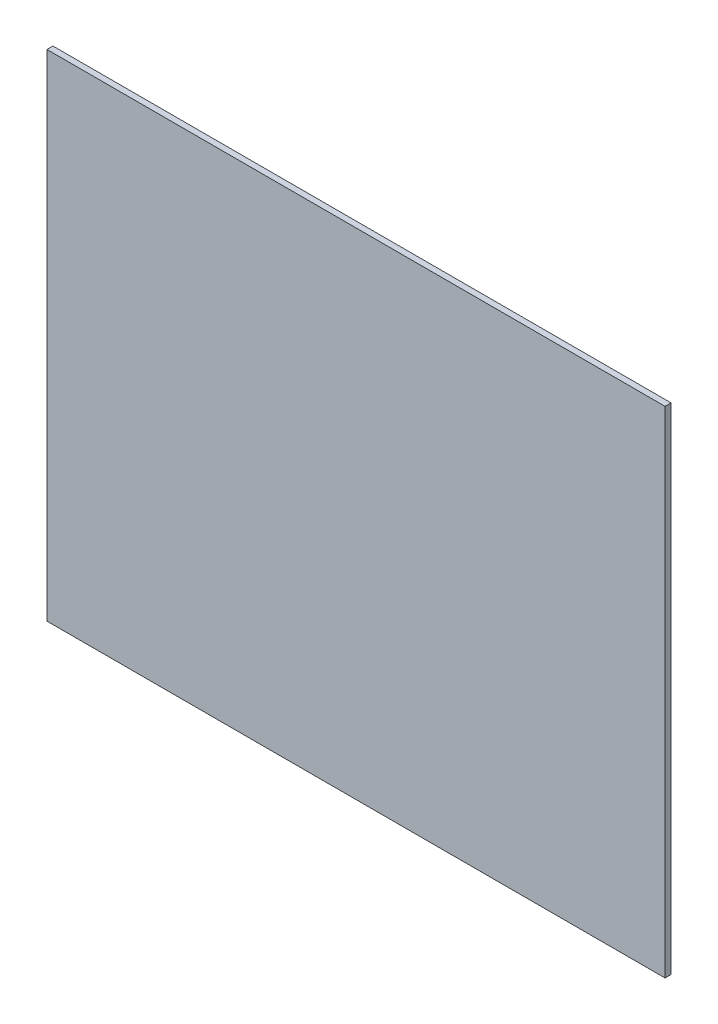
from build123d import *

# Parameters (mm, degrees)
CROQUIS1_W              = 412
CROQUIS1_H              = 330
SALIENTE_EXTRUIR1_DEPTH = 4


with BuildPart() as part:
    # Croquis1 → Saliente-Extruir1 (new body)
    with BuildSketch(Plane.XY):
        with Locations((206, 165)):
            Rectangle(CROQUIS1_W, CROQUIS1_H)
    extrude(amount=SALIENTE_EXTRUIR1_DEPTH)


solid = part.part
